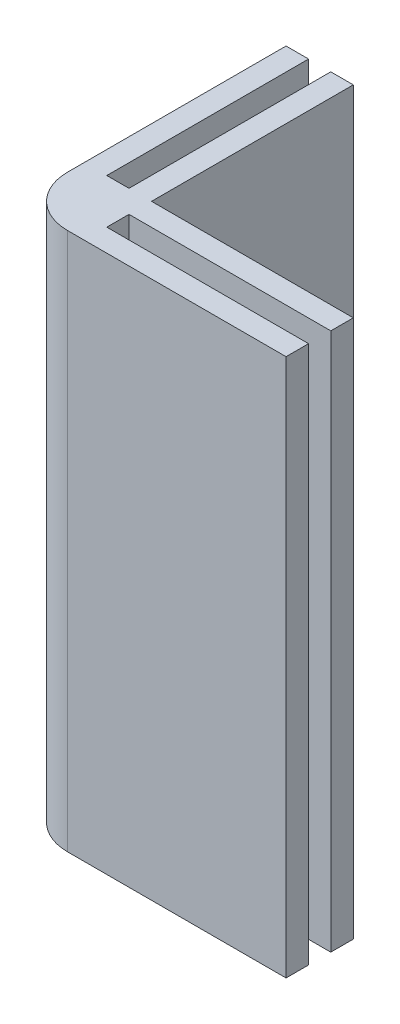
from build123d import *

# Parameters (mm, degrees)
BOSS_EXTRUDE1_DEPTH = 80
FILLET1_R           = 7.5


with BuildPart() as part:
    # Sketch1 → Boss-Extrude1 (new body)
    with BuildSketch(Plane(origin=(0, 0, 0), x_dir=(1, 0, 0), z_dir=(0, 1, 0))):
        Polygon((40, 6.65), (10, 6.65), (10, 3.35), (40, 3.35), (40, 0), (0, 0), (0, 40), (3.35, 40), (3.35, 10), (6.65, 10), (6.65, 40), (10, 40), (10, 10), (40, 10), align=None)
    extrude(amount=BOSS_EXTRUDE1_DEPTH)

    # Fillet1
    fillet1_edges = [part.edges().sort_by_distance(p)[0] for p in [
        (0, 40, 0),
    ]]
    fillet(fillet1_edges, radius=FILLET1_R)


solid = part.part
